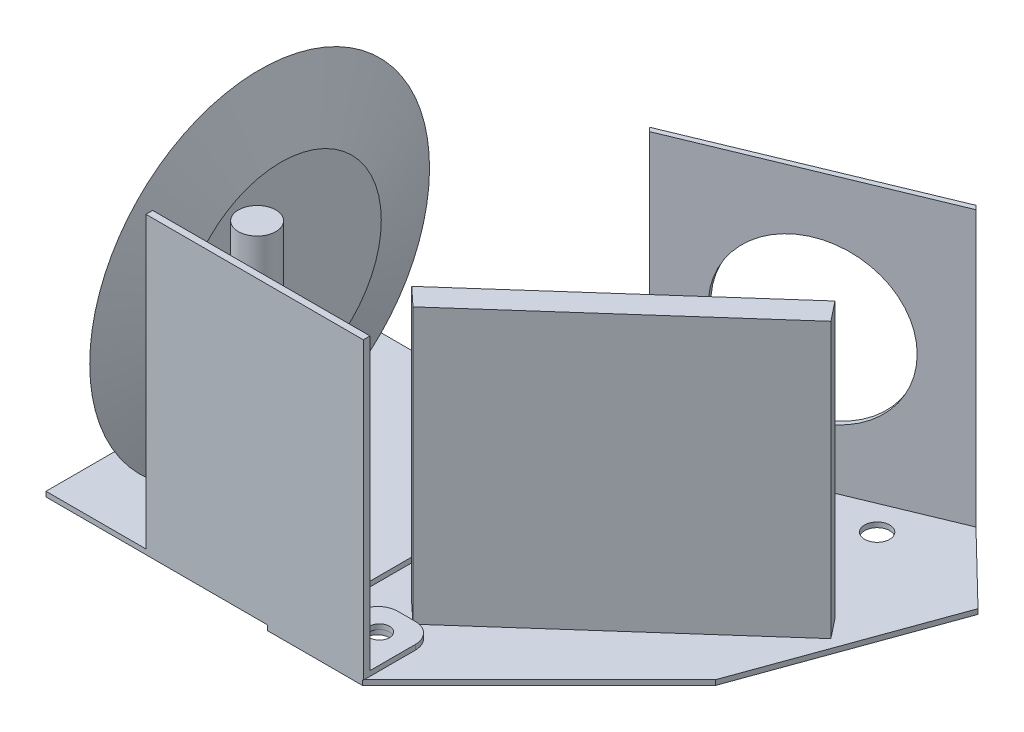
from build123d import *

# Parameters (mm, degrees)
CROQUIS1_R                        = 2
SALIENTE_EXTRUIR1_DEPTH           = 1
CROQUIS2_W                        = 43.5
CROQUIS2_H                        = 1.339346309
SALIENTE_EXTRUIR2_DEPTH           = 58
CROQUIS3_R                        = 2.5
SALIENTE_EXTRUIR3_DEPTH           = 1
SALIENTE_EXTRUIR4_DEPTH           = 55
CROQUIS5_R                        = 16
CORTAR_EXTRUIR1_DEPTH             = 55
SALIENTE_EXTRUIR5_DEPTH           = 55
CROQUIS7_R                        = 34
SALIENTE_EXTRUIR6_DEPTH           = 4.25
SALIENTE_EXTRUIR6_TAPER           = 73
SALIENTE_EXTRUIR6_OTHER_WAY_DEPTH = 4.25
SALIENTE_EXTRUIR6_OTHER_WAY_TAPER = 73
CROQUIS8_R                        = 3.75
SALIENTE_EXTRUIR7_DEPTH           = 58


with BuildPart() as part:
    # Croquis1 → Saliente-Extruir1 (new body)
    with BuildSketch(Plane(origin=(0, 0, 0), x_dir=(1, 0, 0), z_dir=(0, 1, 0))):
        with BuildLine():
            Line((0, 0), (48, 0))
            Line((48, 0), (53, 0))
            Line((53, 0), (63.5, 0))
            Line((63.5, 0), (63.5, 10.4))
            ThreePointArc((63.5, 10.4), (62.328427125, 13.228427125), (59.5, 14.4))
            Line((59.5, 14.4), (56, 14.4))
            ThreePointArc((56, 14.4), (53.171572875, 13.228427125), (52, 10.4))
            Line((52, 10.4), (52, 5.787095104))
            Line((52, 5.787095104), (48, 5.787095104))
            Line((48, 5.787095104), (48, 58))
            ThreePointArc((48, 58), (50.738612788, 67.183300133), (43.417424305, 61))
            Line((43.417424305, 61), (0, 61))
            Line((0, 61), (0, 0))
        make_face()
        with Locations((48, 63)):
            Circle(CROQUIS1_R, mode=Mode.SUBTRACT)
        with Locations((57.75, 8.986759655)):
            Circle(CROQUIS1_R, mode=Mode.SUBTRACT)
    extrude(amount=SALIENTE_EXTRUIR1_DEPTH)

    # Croquis2 → Saliente-Extruir2 (add)
    with BuildSketch(Plane(origin=(0, 1, 0), x_dir=(1, 0, 0), z_dir=(0, 1, 0))):
        with Locations((41.75, 0.669673155)):
            Rectangle(CROQUIS2_W, CROQUIS2_H)
    extrude(amount=SALIENTE_EXTRUIR2_DEPTH)

    # Croquis3 → Saliente-Extruir3 (add)
    with BuildSketch(Plane(origin=(0, 0, 0), x_dir=(-1, 0, 0), z_dir=(0, -1, 0))):
        Polygon((-44.300855822, 65.5), (-44.300855822, 0), (-63.300855822, 0), (-98.656194881, 35.355339059), (-112.599600943, 73.911550328), (-98.25542052, 87.84871245), align=None)
        with Locations((-57.800855822, 8.5)):
            Circle(CROQUIS3_R, mode=Mode.SUBTRACT)
        with Locations((-48.440552847, 62.880089861)):
            Circle(CROQUIS3_R, mode=Mode.SUBTRACT)
        with Locations((-89.246749654, 77.081649496)):
            Circle(CROQUIS3_R, mode=Mode.SUBTRACT)
    extrude(amount=SALIENTE_EXTRUIR3_DEPTH)

    # Croquis6 → Saliente-Extruir5 (add)
    with BuildSketch(Plane(origin=(0, 0, 0), x_dir=(1, 0, 0), z_dir=(0, 1, 0))):
        Polygon((55.082395563, 18.10659262), (99.972967283, 57.916598531), (103.078159084, 53.987437255), (58.758126029, 14.683398339), align=None)
    extrude(amount=SALIENTE_EXTRUIR5_DEPTH)

    # Croquis7 → Saliente-Extruir6 (add)
    with BuildSketch(Plane.ZY.offset(-10)):
        with Locations((-32.75, 28.680559434)):
            Circle(CROQUIS7_R)
    extrude(amount=SALIENTE_EXTRUIR6_DEPTH, taper=SALIENTE_EXTRUIR6_TAPER)

    # Croquis7 → Saliente-Extruir6 other way (add)
    with BuildSketch(Plane.ZY.offset(-10)):
        with Locations((-32.75, 28.680559434)):
            Circle(CROQUIS7_R)
    extrude(amount=-SALIENTE_EXTRUIR6_OTHER_WAY_DEPTH, taper=SALIENTE_EXTRUIR6_OTHER_WAY_TAPER)

    # Croquis8 → Saliente-Extruir7 (add)
    with BuildSketch(Plane(origin=(0, 1, 0), x_dir=(1, 0, 0), z_dir=(0, 1, 0))):
        with Locations((32.25, 10)):
            Circle(CROQUIS8_R)
    extrude(amount=SALIENTE_EXTRUIR7_DEPTH)


with BuildPart() as body_2:
    # Croquis4 → Saliente-Extruir4 (new body)
    with BuildSketch(Plane(origin=(0, 0, 0), x_dir=(1, 0, 0), z_dir=(0, 1, 0))):
        Polygon((51.280406083, 69.473416578), (97.474382708, 88.607588196), (98.25542052, 87.84871245), (52.061443895, 68.714540832), align=None)
    extrude(amount=SALIENTE_EXTRUIR4_DEPTH)

    # Croquis5 → Cortar-Extruir1 (cut)
    with BuildSketch(Plane(origin=(-16.670036955, 0, -40.245029302), x_dir=(0.923879533, 0, -0.382683432), z_dir=(0.382683432, 0, 0.923879533))):
        with Locations((99.394418786, 27.5)):
            Circle(CROQUIS5_R)
    extrude(amount=-CORTAR_EXTRUIR1_DEPTH, mode=Mode.SUBTRACT)


solid = Compound([part.part, body_2.part])
